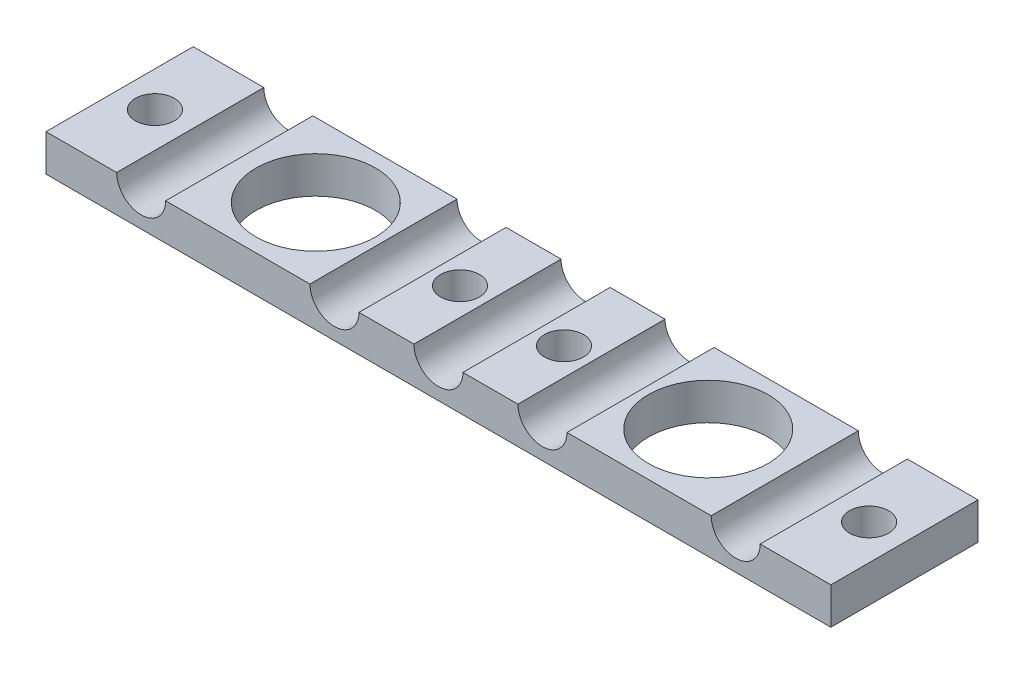
from build123d import *

# Parameters (mm, degrees)
SKETCH1_W                        = 101.6
SKETCH1_H                        = 19.05
EXTRUDE1_DEPTH                   = 4.7625
F_39_64_0_60938_DIAMETER_HOLE1_D = 15.478252
F_1_4_0_25_DIAMETER_HOLE1_D      = 6.35
F_8_0_199_DIAMETER_HOLE1_D       = 5.0546


with BuildPart() as part:
    # Sketch1 → Extrude1 (new body)
    with BuildSketch(Plane(origin=(0, 0, 0), x_dir=(1, 0, 0), z_dir=(0, 1, 0))):
        Rectangle(SKETCH1_W, SKETCH1_H)
    extrude(amount=EXTRUDE1_DEPTH)

    # 39/64 (0.60938) Diameter Hole1 (through all)
    with Locations(Plane(origin=(0, 4.7625, 0), x_dir=(-1, 0, 0), z_dir=(0, 1, 0))):
        with Locations((25.4, 0), (-25.4, 0)):
            Hole(F_39_64_0_60938_DIAMETER_HOLE1_D / 2)

    # 1/4 (0.25) Diameter Hole1 (through all)
    with Locations(Plane.XY.offset(9.525)):
        with Locations((0, 4.7625), (-13.462, 4.7625), (13.462, 4.7625), (-38.481, 4.7625), (38.481, 4.7625)):
            Hole(F_1_4_0_25_DIAMETER_HOLE1_D / 2)

    # #8 (0.199) Diameter Hole1 (through all)
    with Locations(Plane(origin=(0, 4.7625, 0), x_dir=(-1, 0, 0), z_dir=(0, 1, 0))):
        with Locations((-46.228, 0), (-6.731, 0), (6.731, 0), (46.228, 0)):
            Hole(F_8_0_199_DIAMETER_HOLE1_D / 2)


solid = part.part
